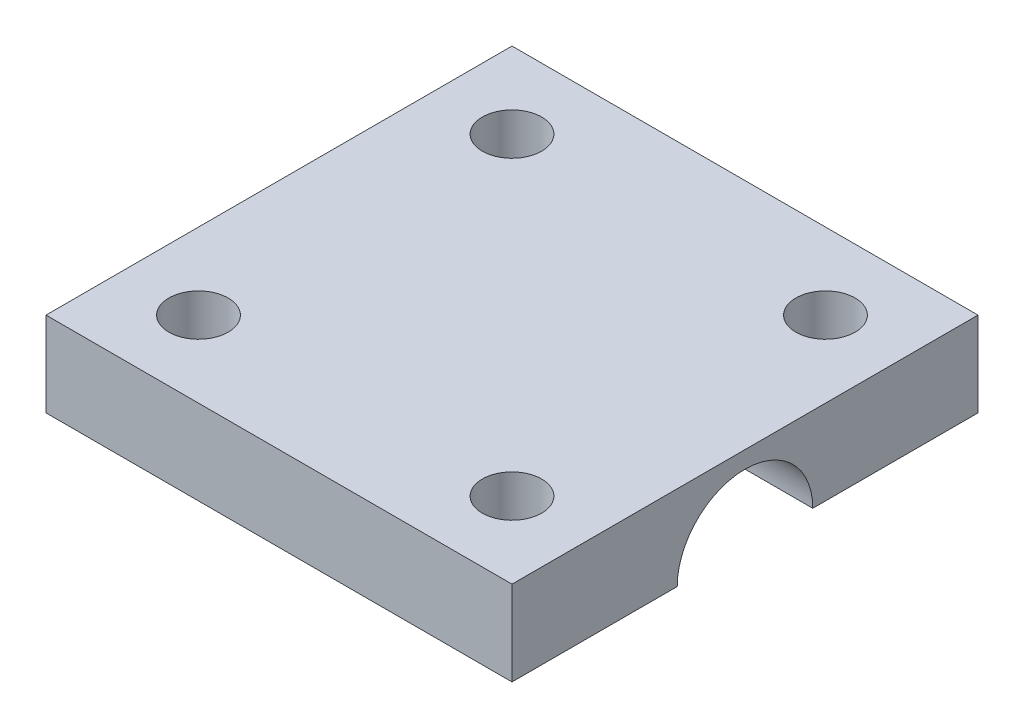
from build123d import *

# Parameters (mm, degrees)
SKETCH1_W           = 55
SKETCH1_H           = 55
BOSS_EXTRUDE1_DEPTH = 10
SKETCH2_R           = 8
CUT_EXTRUDE1_DEPTH  = 50
SKETCH3_R           = 3.5
CUT_EXTRUDE2_DEPTH  = 50


with BuildPart() as part:
    # Sketch1 → Boss-Extrude1 (new body)
    with BuildSketch(Plane(origin=(0, 0, 0), x_dir=(1, 0, 0), z_dir=(0, 1, 0))):
        Rectangle(SKETCH1_W, SKETCH1_H)
    extrude(amount=BOSS_EXTRUDE1_DEPTH)

    # Sketch2 → Cut-Extrude1 (cut)
    with BuildSketch(Plane(origin=(27.5, 0, 0), x_dir=(0, 0, -1), z_dir=(1, 0, 0))):
        Circle(SKETCH2_R)
    extrude(amount=-CUT_EXTRUDE1_DEPTH, mode=Mode.SUBTRACT)

    # Sketch3 → Cut-Extrude2 (cut)
    with BuildSketch(Plane(origin=(0, 10, 0), x_dir=(1, 0, 0), z_dir=(0, 1, 0))):
        with Locations((-18.5, 18.5)):
            Circle(SKETCH3_R)
        with Locations((18.5, 18.5)):
            Circle(SKETCH3_R)
        with Locations((-18.5, -18.5)):
            Circle(SKETCH3_R)
        with Locations((18.5, -18.5)):
            Circle(SKETCH3_R)
    extrude(amount=-CUT_EXTRUDE2_DEPTH, mode=Mode.SUBTRACT)


solid = part.part
